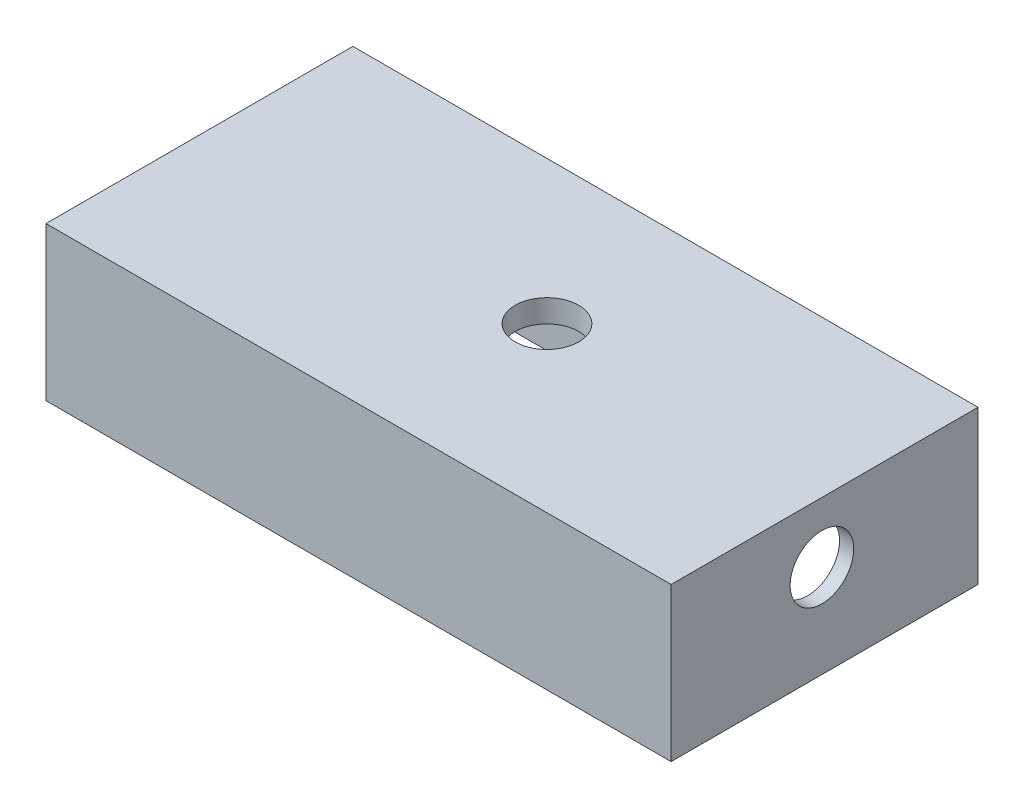
from build123d import *

# Parameters (mm, degrees)
SKETCH1_W           = 349.25
SKETCH1_H           = 171.45
BOSS_EXTRUDE1_DEPTH = 85.725
CUT_EXTRUDE1_DEPTH  = 73.025
CUT_EXTRUDE2_REACH  = 87.725
SKETCH5_R           = 17.749738032
CUT_EXTRUDE3_REACH  = 351.25
SKETCH6_R           = 17.749738032
CHAMFER1_SIZE       = 0.635


with BuildPart() as part:
    # Sketch1 → Boss-Extrude1 (new body)
    with BuildSketch(Plane(origin=(0, 0, 0), x_dir=(1, 0, 0), z_dir=(0, 1, 0))):
        Rectangle(SKETCH1_W, SKETCH1_H)
    extrude(amount=BOSS_EXTRUDE1_DEPTH)

    # Sketch2 → Cut-Extrude1 (cut)
    with BuildSketch(Plane.XZ):
        with BuildLine():
            Line((143.166535328, 77.827138829), (-143.166535328, 77.827138829))
            ThreePointArc((-143.166535328, 77.827138829), (-159.826397833, 70.926397833), (-166.727138829, 54.266535328))
            Line((-166.727138829, 54.266535328), (-166.727138829, -54.266535328))
            ThreePointArc((-166.727138829, -54.266535328), (-159.826397833, -70.926397833), (-143.166535328, -77.827138829))
            Line((-143.166535328, -77.827138829), (143.166535328, -77.827138829))
            ThreePointArc((143.166535328, -77.827138829), (159.826397833, -70.926397833), (166.727138829, -54.266535328))
            Line((166.727138829, -54.266535328), (166.727138829, 54.266535328))
            ThreePointArc((166.727138829, 54.266535328), (159.826397833, 70.926397833), (143.166535328, 77.827138829))
        make_face()
    extrude(amount=-CUT_EXTRUDE1_DEPTH, mode=Mode.SUBTRACT)

    # Sketch5 → Cut-Extrude2 (cut, up to next)
    with BuildSketch(Plane(origin=(0, 85.725, 0), x_dir=(1, 0, 0), z_dir=(0, 1, 0)), mode=Mode.PRIVATE) as cut_extrude2_sk1:
        with Locations((13.724333657, 5.811180929)):
            Circle(SKETCH5_R)
    cut_extrude2_tool1 = extrude(cut_extrude2_sk1.sketch, amount=-CUT_EXTRUDE2_REACH, mode=Mode.PRIVATE) & part.part
    add(cut_extrude2_tool1.solids().sort_by_distance((13.724334, 85.725, -5.811181))[0], mode=Mode.SUBTRACT)

    # Sketch6 → Cut-Extrude3 (cut, up to next)
    with BuildSketch(Plane(origin=(174.625, 0, 0), x_dir=(0, 0, -1), z_dir=(1, 0, 0)), mode=Mode.PRIVATE) as cut_extrude3_sk1:
        with Locations((-1.47611621, 51.972642264)):
            Circle(SKETCH6_R)
    cut_extrude3_tool1 = extrude(cut_extrude3_sk1.sketch, amount=-CUT_EXTRUDE3_REACH, mode=Mode.PRIVATE) & part.part
    add(cut_extrude3_tool1.solids().sort_by_distance((174.625, 51.972642, 1.476116))[0], mode=Mode.SUBTRACT)

    # Chamfer1
    chamfer1_edges = [part.edges().sort_by_distance(p)[0] for p in [
        (159.826397833, 0, 70.926397833),
        (159.826397833, 0, -70.926397833),
        (-159.826397833, 0, -70.926397833),
        (0, 0, 77.827138829),
        (-159.826397833, 0, 70.926397833),
        (-166.727138829, 0, 0),
        (0, 0, -77.827138829),
        (166.727138829, 0, 0),
    ]]
    chamfer(chamfer1_edges, length=CHAMFER1_SIZE)


solid = part.part
